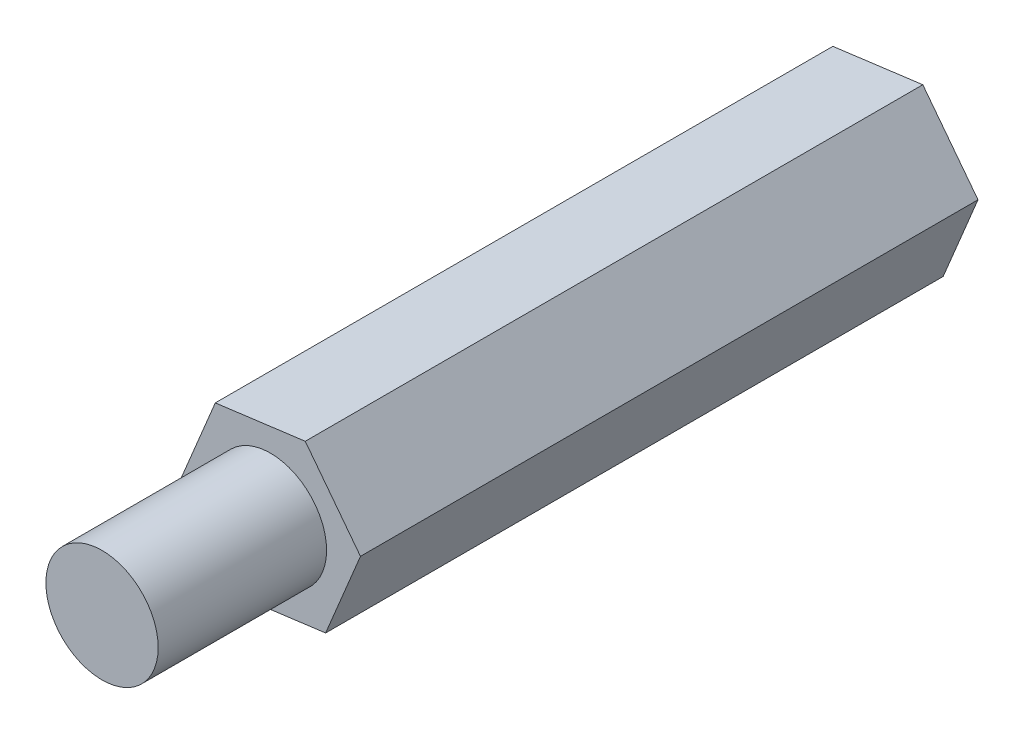
from build123d import *

# Parameters (mm, degrees)
EXTRUDE_1_DEPTH     = 11
SKETCH_2_R          = 1
EXTRUDE_2_DEPTH     = 3
SKETCH_3_R          = 1
CUT_EXTRUDE_1_DEPTH = 3


with BuildPart() as part:
    # 草图1 → 凸台-拉伸1 (new body)
    with BuildSketch(Plane.XY):
        Polygon((0.982850318, -1.283486886), (1.602957407, 0.209429901), (0.62010709, 1.492916786), (-0.982850318, 1.283486886), (-1.602957407, -0.209429901), (-0.62010709, -1.492916786), align=None)
    extrude(amount=EXTRUDE_1_DEPTH)

    # 草图2 → 凸台-拉伸2 (add)
    with BuildSketch(Plane.XY.offset(11)):
        Circle(SKETCH_2_R)
    extrude(amount=EXTRUDE_2_DEPTH)

    # 草图3 → 切除-拉伸1 (cut)
    with BuildSketch(Plane(origin=(0, 0, 0), x_dir=(-1, 0, 0), z_dir=(0, 0, -1))):
        Circle(SKETCH_3_R)
    extrude(amount=-CUT_EXTRUDE_1_DEPTH, mode=Mode.SUBTRACT)


solid = part.part
